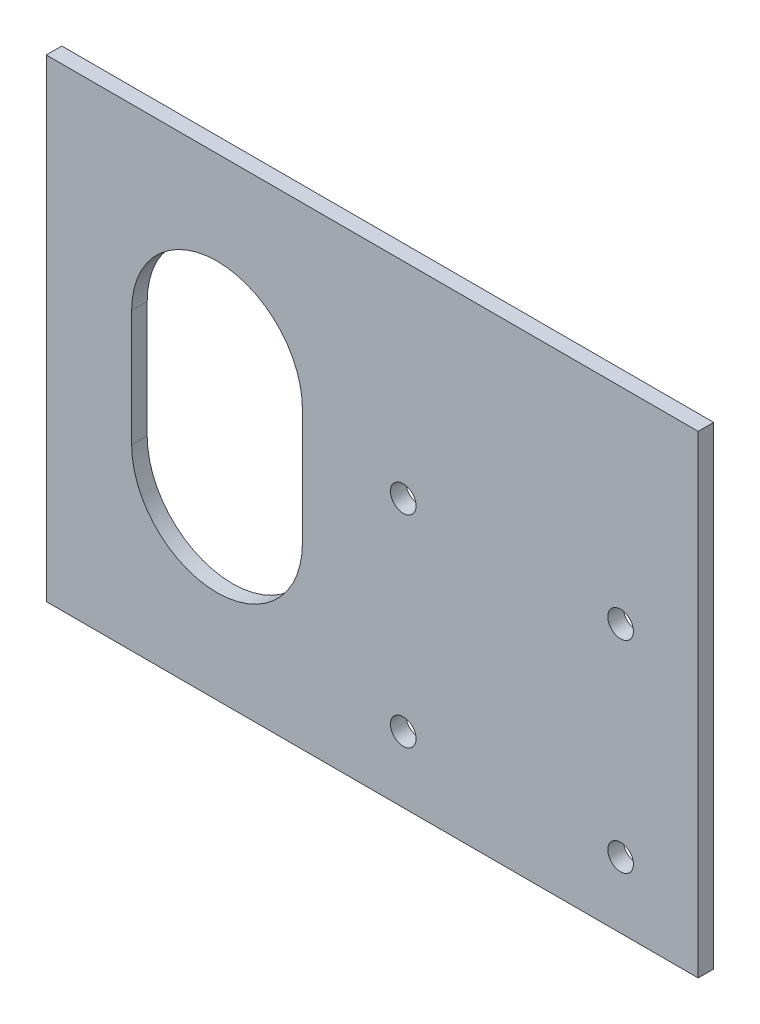
from build123d import *

# Parameters (mm, degrees)
SKETCH1_W           = 84
SKETCH1_H           = 61
SKETCH1_R           = 1.65
BOSS_EXTRUDE1_DEPTH = 2


with BuildPart() as part:
    # Sketch1 → Boss-Extrude1 (new body)
    with BuildSketch(Plane.XY):
        with Locations((-110.4, 45.7)):
            Rectangle(SKETCH1_W, SKETCH1_H)
        with Locations((-106.4, 23.7)):
            Circle(SKETCH1_R, mode=Mode.SUBTRACT)
        with Locations((-78.4, 23.7)):
            Circle(SKETCH1_R, mode=Mode.SUBTRACT)
        with Locations((-78.4, 49.7)):
            Circle(SKETCH1_R, mode=Mode.SUBTRACT)
        with Locations((-106.4, 49.7)):
            Circle(SKETCH1_R, mode=Mode.SUBTRACT)
        with BuildLine():
            Line((-119.4, 53.2), (-119.4, 38.2))
            ThreePointArc((-119.4, 38.2), (-130.4, 27.2), (-141.4, 38.2))
            Line((-141.4, 38.2), (-141.4, 53.2))
            ThreePointArc((-141.4, 53.2), (-130.4, 64.2), (-119.4, 53.2))
        make_face(mode=Mode.SUBTRACT)
    extrude(amount=BOSS_EXTRUDE1_DEPTH)


solid = part.part
